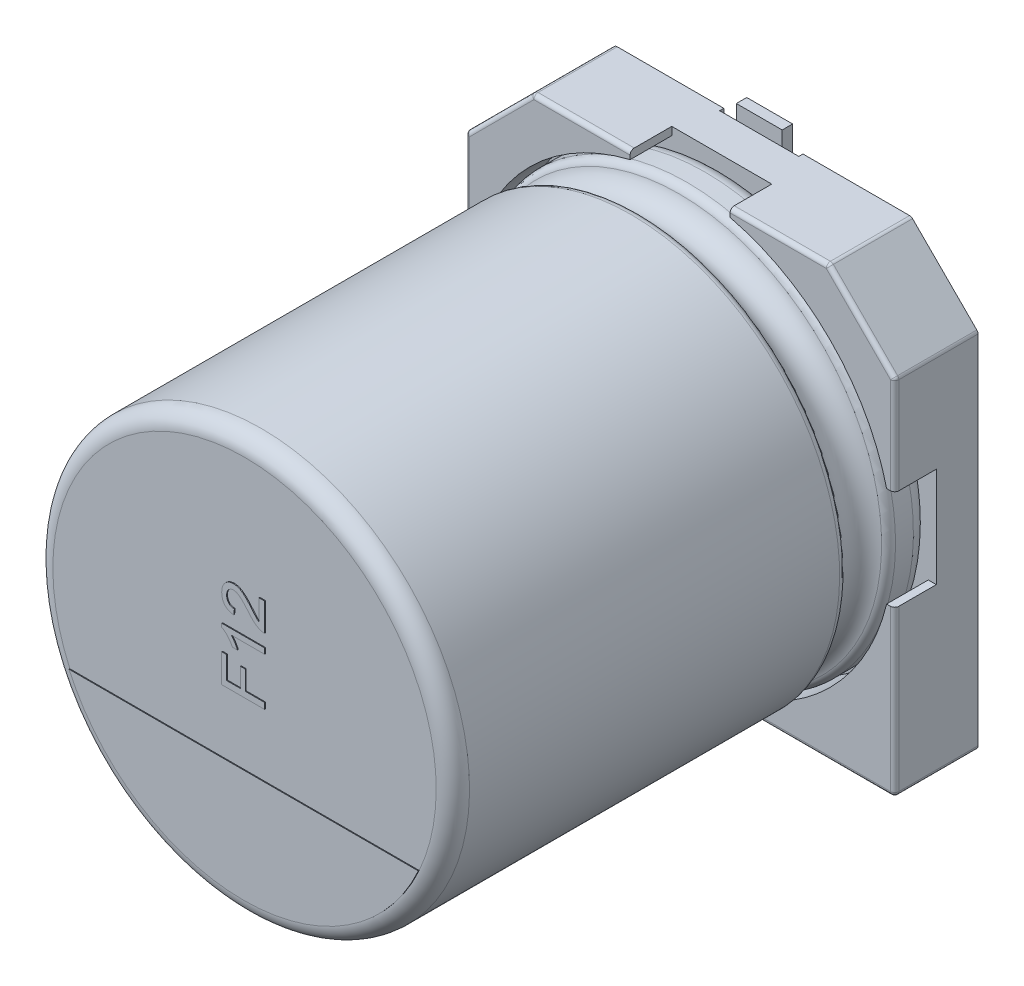
from build123d import *

# Parameters (mm, degrees)
BOSS_EXTRUDE1_DEPTH  = 1
BOSS_EXTRUDE2_DEPTH  = 1
SKETCH7_R            = 0.35
SPACER_PAD_DEPTH     = 0.15
SKETCH9_W            = 1.9
SKETCH9_H            = 3.05
CUT_EXTRUDE1_DEPTH   = 0.1
FILLET1_R            = 0.1
FILLET2_R            = 0.1
CATHODE_MARKER_DEPTH = 0.02
TEXT_2_DEPTH         = 0.02
SKETCH19_W           = 1.1
SKETCH19_H           = 3.2
BOSS_EXTRUDE6_DEPTH  = 0.25


with BuildPart() as part:
    # Sketch2 → Boss-Extrude1 (new body)
    with BuildSketch(Plane.XY):
        Polygon((-5.15, 3.55), (-3.55, 5.15), (3.55, 5.15), (5.15, 3.55), (5.15, -5.15), (-5.15, -5.15), align=None)
    extrude(amount=BOSS_EXTRUDE1_DEPTH)

    # Sketch4 → Boss-Extrude2 (add)
    with BuildSketch(Plane.XY.offset(1)):
        with BuildLine():
            Line((-5.15, 3.55), (-3.55, 5.15))
            Line((-3.55, 5.15), (-1.2, 5.15))
            Line((-1.2, 5.15), (-1.2, 4.956813493))
            ThreePointArc((-1.2, 4.956813493), (-3.606244584, 3.606244584), (-4.956813493, 1.2))
            Line((-4.956813493, 1.2), (-5.15, 1.2))
            Line((-5.15, 1.2), (-5.15, 3.55))
        make_face()
        with BuildLine():
            Line((3.55, 5.15), (5.15, 3.55))
            Line((5.15, 3.55), (5.15, 1.2))
            Line((5.15, 1.2), (4.956813493, 1.2))
            ThreePointArc((4.956813493, 1.2), (3.606244584, 3.606244584), (1.2, 4.956813493))
            Line((1.2, 4.956813493), (1.2, 5.15))
            Line((1.2, 5.15), (3.55, 5.15))
        make_face()
        with BuildLine():
            Line((5.15, -1.2), (5.15, -5.15))
            Line((5.15, -5.15), (1.2, -5.15))
            Line((1.2, -5.15), (1.2, -4.956813493))
            ThreePointArc((1.2, -4.956813493), (3.606244584, -3.606244584), (4.956813493, -1.2))
            Line((4.956813493, -1.2), (5.15, -1.2))
        make_face()
        with BuildLine():
            Line((-5.15, -1.2), (-5.15, -5.15))
            Line((-5.15, -5.15), (-1.2, -5.15))
            Line((-1.2, -5.15), (-1.2, -4.956813493))
            ThreePointArc((-1.2, -4.956813493), (-3.606244584, -3.606244584), (-4.956813493, -1.2))
            Line((-4.956813493, -1.2), (-5.15, -1.2))
        make_face()
    extrude(amount=BOSS_EXTRUDE2_DEPTH)

    # Sketch7 → Spacer Pad (add)
    with BuildSketch(Plane(origin=(0, 0, 0), x_dir=(1, 0, 0), z_dir=(0, 0, -1))):
        with Locations((-3.581612435, 3.54735769)):
            Circle(SKETCH7_R)
        with Locations((3.581612435, 3.54735769)):
            Circle(SKETCH7_R)
        with Locations((-3.581612435, -3.54735769)):
            Circle(SKETCH7_R)
        with Locations((3.581612435, -3.54735769)):
            Circle(SKETCH7_R)
    extrude(amount=SPACER_PAD_DEPTH)

    # Sketch9 → Cut-Extrude1 (cut)
    with BuildSketch(Plane(origin=(0, 0, 0), x_dir=(1, 0, 0), z_dir=(0, 0, -1))):
        with Locations((0, 3.625)):
            Rectangle(SKETCH9_W, SKETCH9_H)
        with Locations((0, -3.625)):
            Rectangle(SKETCH9_W, SKETCH9_H)
    extrude(amount=-CUT_EXTRUDE1_DEPTH, mode=Mode.SUBTRACT)

    # Fillet1
    fillet1_edges = [part.edges().sort_by_distance(p)[0] for p in [
        (5.15, -5.15, 1),
        (-5.15, -5.15, 1),
        (-5.15, 3.55, 1),
        (-3.55, 5.15, 1),
        (3.55, 5.15, 1),
        (5.15, 3.55, 1),
    ]]
    fillet(fillet1_edges, radius=FILLET1_R)

    # Sketch10 → Revolve1 (revolve)
    with BuildSketch(Plane(origin=(0, 0, 0), x_dir=(0, 0, -1), z_dir=(1, 0, 0))):
        with BuildLine():
            Line((-12.453626625, 0), (-1, 0))
            Line((-1, 0), (-1, 4.6))
            ThreePointArc((-1, 4.6), (-1.117157288, 4.882842712), (-1.4, 5))
            Line((-1.4, 5), (-1.829179607, 5))
            ThreePointArc((-1.829179607, 5), (-1.948702468, 4.960356745), (-2.020842576, 4.857142857))
            ThreePointArc((-2.020842576, 4.857142857), (-2.5, 4.5), (-2.979157424, 4.857142857))
            ThreePointArc((-2.979157424, 4.857142857), (-3.051297532, 4.960356745), (-3.170820393, 5))
            Line((-3.170820393, 5), (-12.053626625, 5))
            ThreePointArc((-12.053626625, 5), (-12.336469337, 4.882842712), (-12.453626625, 4.6))
            Line((-12.453626625, 4.6), (-12.453626625, 0))
        make_face()
    revolve(axis=Axis((0, 0, -18.9630778), (0, 0, 1)))

    # Fillet2
    fillet2_edges = [part.edges().sort_by_distance(p)[0] for p in [
        (3.125, -5.15, 2),
        (5.120710678, -5.120710678, 2),
        (5.15, 2.354289322, 2),
        (5.142387953, 3.546846987, 2),
        (2.354289322, 5.15, 2),
        (3.546846987, 5.142387953, 2),
        (-2.354289322, 5.15, 2),
        (-3.546846987, 5.142387953, 2),
        (-4.35, 4.35, 2),
        (-5.142387953, 3.546846987, 2),
        (-5.15, -3.125, 2),
        (-5.120710678, -5.120710678, 2),
        (5.15, -3.125, 2),
        (4.35, 4.35, 2),
        (-5.15, 2.354289322, 2),
        (-3.125, -5.15, 2),
    ]]
    fillet(fillet2_edges, radius=FILLET2_R)

    # Sketch13 → Cathode marker (add)
    with BuildSketch(Plane.XY.offset(12.453626625)):
        with BuildLine():
            Line((-4.192254052, -1.893411197), (4.192254052, -1.893411197))
            ThreePointArc((4.192254052, -1.893411197), (0, -4.6), (-4.192254052, -1.893411197))
        make_face()
    extrude(amount=CATHODE_MARKER_DEPTH)

    # Sketch15 → Text 2 (add)
    with BuildSketch(Plane.XY.offset(12.453626625)):
        Polygon((0.5, -0.381462215), (-0.527327474, -0.381462215), (-0.527327474, 0.303422768), (-0.408789689, 0.303422768), (-0.408789689, -0.236582699), (-0.079518062, -0.236582699), (-0.079518062, 0.224397578), (0.039019723, 0.224397578), (0.039019723, -0.236582699), (0.5, -0.236582699), align=None)
        with BuildLine():
            Line((0.5, 0.896111695), (0.5, 0.764403045))
            Line((0.5, 0.764403045), (-0.300541641, 0.764403045))
            add(Edge.make_bspline(
                [(-0.300541641, 0.764403045), (-0.293231008, 0.756817032), (-0.278036657, 0.741050337), (-0.256498368, 0.714475277), (-0.234933587, 0.684610718), (-0.213972558, 0.652175414), (-0.193975357, 0.619214042), (-0.17626551, 0.587187237), (-0.16122985, 0.556879913), (-0.153017422, 0.536910016), (-0.149076693, 0.527327474)],
                knots=[0, 0, 0, 0, 0.893410138, 1.856855062, 2.898678959, 4.017251132, 5.132047586, 6.168690112, 7.121247105, 8, 8, 8, 8], degree=3))
            Line((-0.149076693, 0.527327474), (-0.270495605, 0.527327474))
            add(Edge.make_bspline(
                [(-0.270495605, 0.527327474), (-0.278975965, 0.543782432), (-0.295690253, 0.576214181), (-0.324502419, 0.622123276), (-0.356038954, 0.664767274), (-0.389687464, 0.703892734), (-0.424153619, 0.73878416), (-0.458713989, 0.768417729), (-0.492500166, 0.79301833), (-0.516061848, 0.805402816), (-0.527327474, 0.811324252)],
                knots=[0, 0, 0, 0, 1.141359047, 2.249551097, 3.338622382, 4.409719606, 5.42990334, 6.36011437, 7.215916014, 8, 8, 8, 8], degree=3))
            Line((-0.527327474, 0.811324252), (-0.527327474, 0.896111695))
            Line((-0.527327474, 0.896111695), (0.5, 0.896111695))
        make_face()
        with BuildLine():
            Line((0.368291349, 1.870755709), (0.5, 1.870755709))
            Line((0.5, 1.870755709), (0.5, 1.199041592))
            add(Edge.make_bspline(
                [(0.5, 1.199041592), (0.492171624, 1.199023328), (0.476609384, 1.198987021), (0.453503009, 1.201686459), (0.430681783, 1.205754477), (0.415992941, 1.21046681), (0.408627124, 1.212829841)],
                knots=[0, 0, 0, 0, 1.010600758, 2.009000657, 3.001600101, 4, 4, 4, 4], degree=3))
            add(Edge.make_bspline(
                [(0.408627124, 1.212829841), (0.396584863, 1.217176307), (0.372122637, 1.226005565), (0.336858288, 1.244163875), (0.301599244, 1.26511474), (0.272965244, 1.285789183), (0.250100299, 1.30463958), (0.232215155, 1.320455426), (0.213906424, 1.337980122), (0.195178947, 1.357202211), (0.175910995, 1.377935939), (0.156038437, 1.400209816), (0.135931585, 1.424286799), (0.122603928, 1.441095056), (0.115781171, 1.449699617)],
                knots=[0, 0, 0, 0, 1.204682444, 2.447149603, 3.728063212, 5.065745198, 5.768097617, 6.518745349, 7.313897871, 8.154576377, 9.046034033, 9.979646649, 10.965731253, 12, 12, 12, 12], degree=3))
            add(Edge.make_bspline(
                [(0.115781171, 1.449699617), (0.104655179, 1.462918347), (0.083231375, 1.488371851), (0.051440447, 1.524316206), (0.021920728, 1.557145453), (-0.005844993, 1.586337131), (-0.031587993, 1.612129), (-0.055248077, 1.634584788), (-0.076757278, 1.653887768), (-0.096875759, 1.669833062), (-0.115869126, 1.683180838), (-0.134293391, 1.694769626), (-0.152793693, 1.704072731), (-0.171018699, 1.712056193), (-0.189040379, 1.718249837), (-0.207020154, 1.722608759), (-0.224787825, 1.72542549), (-0.236666661, 1.72572763), (-0.242507517, 1.725876194)],
                knots=[0, 0, 0, 0, 1.782511555, 3.432339066, 4.950556168, 6.337242158, 7.588364383, 8.709771971, 9.70247892, 10.569050646, 11.3564271, 12.096888545, 12.812232926, 13.490631961, 14.148641375, 14.7751826, 15.397753892, 16, 16, 16, 16], degree=3))
            add(Edge.make_bspline(
                [(-0.242507517, 1.725876194), (-0.248281178, 1.725733206), (-0.259608786, 1.725452673), (-0.276186441, 1.722790437), (-0.292152005, 1.719085603), (-0.3072139, 1.71309136), (-0.321833794, 1.705972389), (-0.335535371, 1.696748544), (-0.348836285, 1.686307816), (-0.361041005, 1.674110876), (-0.372476027, 1.660880458), (-0.382043562, 1.646159372), (-0.39031717, 1.630672527), (-0.397264619, 1.614262991), (-0.402301048, 1.596687495), (-0.405976885, 1.578168823), (-0.408302294, 1.558691766), (-0.40862476, 1.545400752), (-0.408789689, 1.538602956)],
                knots=[0, 0, 0, 0, 0.987973548, 1.938350371, 2.870100611, 3.788647624, 4.708095761, 5.649791829, 6.611214459, 7.599816467, 8.600146238, 9.60047601, 10.599079585, 11.604913276, 12.645813302, 13.724097821, 14.835971573, 16, 16, 16, 16], degree=3))
            add(Edge.make_bspline(
                [(-0.408789689, 1.538602956), (-0.40862557, 1.53146206), (-0.408304378, 1.517486801), (-0.405969781, 1.497057642), (-0.402394194, 1.477667728), (-0.396958126, 1.459344795), (-0.390017565, 1.442207301), (-0.381660425, 1.426053384), (-0.371833372, 1.411002929), (-0.360287899, 1.39726903), (-0.347459849, 1.384859189), (-0.333496156, 1.373849729), (-0.318088523, 1.364758184), (-0.301533418, 1.357412081), (-0.28393451, 1.351357624), (-0.265117004, 1.34701711), (-0.245105463, 1.344641338), (-0.231400392, 1.344164669), (-0.224397578, 1.343921107)],
                knots=[0, 0, 0, 0, 1.130801575, 2.213061782, 3.252933619, 4.249917472, 5.234510032, 6.17726912, 7.126517163, 8.075267631, 9.012689889, 9.949419277, 10.884824487, 11.837981854, 12.813782694, 13.828488442, 14.890433304, 16, 16, 16, 16], degree=3))
            Line((-0.224397578, 1.343921107), (-0.237568443, 1.212212457))
            add(Edge.make_bspline(
                [(-0.237568443, 1.212212457), (-0.24904719, 1.213560002), (-0.271378105, 1.216181537), (-0.303720398, 1.222711809), (-0.333809028, 1.231878297), (-0.362058757, 1.242851592), (-0.388005438, 1.256590295), (-0.412169544, 1.272210223), (-0.433950691, 1.290416564), (-0.453727379, 1.31067706), (-0.470891467, 1.333200406), (-0.486127765, 1.357451274), (-0.498828506, 1.38371236), (-0.509361258, 1.41173301), (-0.517348257, 1.441596614), (-0.523076894, 1.473255605), (-0.526607783, 1.506762393), (-0.527084154, 1.529745046), (-0.527327474, 1.541484083)],
                knots=[0, 0, 0, 0, 1.130730993, 2.199739822, 3.223355253, 4.205635214, 5.160465258, 6.091399258, 7.016214058, 7.932437584, 8.856204186, 9.781944312, 10.73064304, 11.705670886, 12.707145581, 13.751268262, 14.851396981, 16, 16, 16, 16], degree=3))
            add(Edge.make_bspline(
                [(-0.527327474, 1.541484083), (-0.52712405, 1.553363635), (-0.526727779, 1.576505072), (-0.522673132, 1.610225866), (-0.516358058, 1.642042368), (-0.507556774, 1.672071209), (-0.496015678, 1.700135005), (-0.481915024, 1.726255234), (-0.465392543, 1.750552728), (-0.446249206, 1.772620062), (-0.425353076, 1.792522914), (-0.403045107, 1.80994989), (-0.37940145, 1.824605803), (-0.354725388, 1.836849826), (-0.328682822, 1.846210946), (-0.301469318, 1.85262614), (-0.273039491, 1.857038395), (-0.253637851, 1.857400273), (-0.243742286, 1.857584844)],
                knots=[0, 0, 0, 0, 1.195413282, 2.328672114, 3.413490698, 4.457927086, 5.473612634, 6.462365753, 7.441157041, 8.42539015, 9.397434444, 10.3422866, 11.269742116, 12.193178192, 13.110630063, 14.048592791, 15.004708964, 16, 16, 16, 16], degree=3))
            add(Edge.make_bspline(
                [(-0.243742286, 1.857584844), (-0.233575811, 1.857302367), (-0.213220425, 1.856736788), (-0.182799605, 1.852301499), (-0.152753848, 1.844785725), (-0.122679161, 1.834603427), (-0.092323518, 1.821055969), (-0.061437605, 1.803643495), (-0.029892588, 1.782242308), (-0.003243258, 1.761442109), (0.019225253, 1.742271593), (0.037719176, 1.725136622), (0.057588605, 1.70555045), (0.079062929, 1.68379259), (0.101646668, 1.659321277), (0.125957864, 1.632711563), (0.151384518, 1.603409475), (0.168753578, 1.583066868), (0.177725396, 1.572559093)],
                knots=[0, 0, 0, 0, 0.927158598, 1.856363277, 2.797335015, 3.749167701, 4.749227661, 5.825023649, 6.979171586, 8.223362362, 8.906844726, 9.672958766, 10.52256342, 11.451810239, 12.461281865, 13.559912207, 14.739596516, 16, 16, 16, 16], degree=3))
            add(Edge.make_bspline(
                [(0.177725396, 1.572559093), (0.185029786, 1.563543213), (0.198985808, 1.546317162), (0.219510177, 1.522134973), (0.237812789, 1.500046924), (0.25415447, 1.480325135), (0.268864412, 1.463129444), (0.281772612, 1.448450906), (0.292659395, 1.436022029), (0.309621164, 1.417462837), (0.333822946, 1.394033883), (0.357137714, 1.376562897), (0.368291349, 1.36820489)],
                knots=[0, 0, 0, 0, 1.242067915, 2.373138023, 3.395138797, 4.312776638, 5.114836229, 5.81737152, 6.405241861, 6.883397567, 8.50903741, 10, 10, 10, 10], degree=3))
            Line((0.368291349, 1.36820489), (0.368291349, 1.870755709))
        make_face()
    extrude(amount=TEXT_2_DEPTH)

    # Sketch19 → Boss-Extrude6 (add)
    with BuildSketch(Plane(origin=(0, 0, 0.1), x_dir=(1, 0, 0), z_dir=(0, 0, -1))):
        with Locations((0, 3.9)):
            Rectangle(SKETCH19_W, SKETCH19_H)
        with Locations((0, -3.9)):
            Rectangle(SKETCH19_W, SKETCH19_H)
    extrude(amount=BOSS_EXTRUDE6_DEPTH)


solid = part.part
